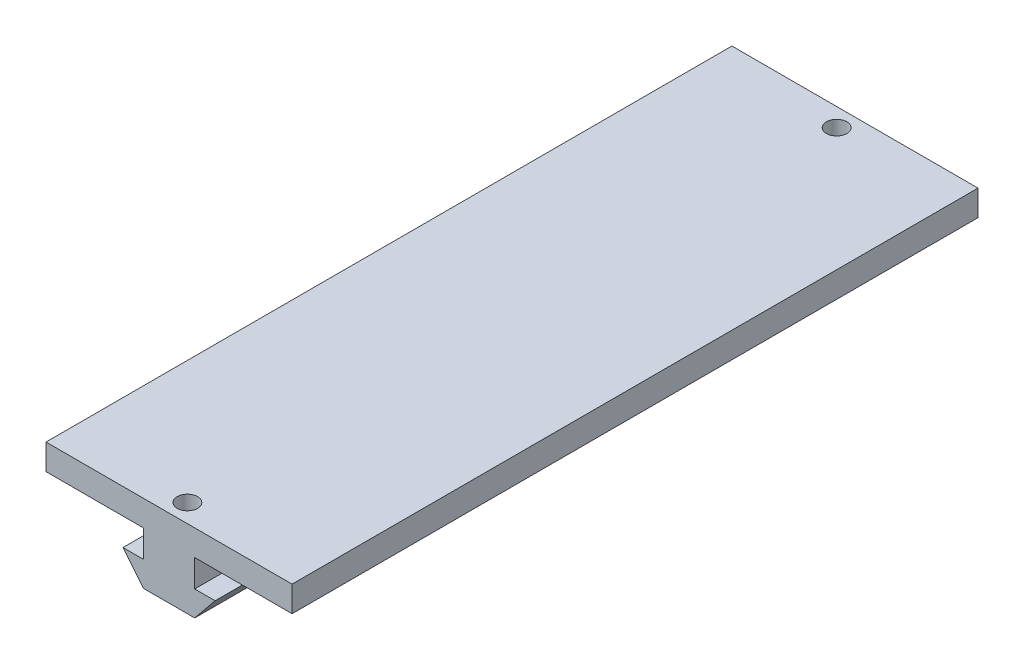
from build123d import *

# Parameters (mm, degrees)
SKETCH1_W           = 47
SKETCH1_H           = 131
BOSS_EXTRUDE1_DEPTH = 4.9
BOSS_EXTRUDE2_DEPTH = 50
SKETCH2_R           = 1.95
CUT_EXTRUDE1_DEPTH  = 6


with BuildPart() as part:
    # Sketch1 → Boss-Extrude1 (new body)
    with BuildSketch(Plane(origin=(0, 0, 0), x_dir=(1, 0, 0), z_dir=(0, 1, 0))):
        Rectangle(SKETCH1_W, SKETCH1_H)
    extrude(amount=BOSS_EXTRUDE1_DEPTH)

    # Sketch3 → Boss-Extrude2 (add)
    with BuildSketch(Plane.XY.offset(65.5)):
        Polygon((-4.9, 0), (4.9, 0), (4.9, -5.2), (8.8, -5.2), (4.9, -10), (-4.9, -10), (-8.8, -5.2), (-4.9, -5.2), align=None)
    extrude(amount=-BOSS_EXTRUDE2_DEPTH)

    # Sketch2 → Cut-Extrude1 (cut)
    with BuildSketch(Plane(origin=(0, 4.9, 0), x_dir=(1, 0, 0), z_dir=(0, 1, 0))):
        with Locations((0, 62)):
            Circle(SKETCH2_R)
        with Locations((0, -62)):
            Circle(SKETCH2_R)
    extrude(amount=-CUT_EXTRUDE1_DEPTH, mode=Mode.SUBTRACT)


solid = part.part
